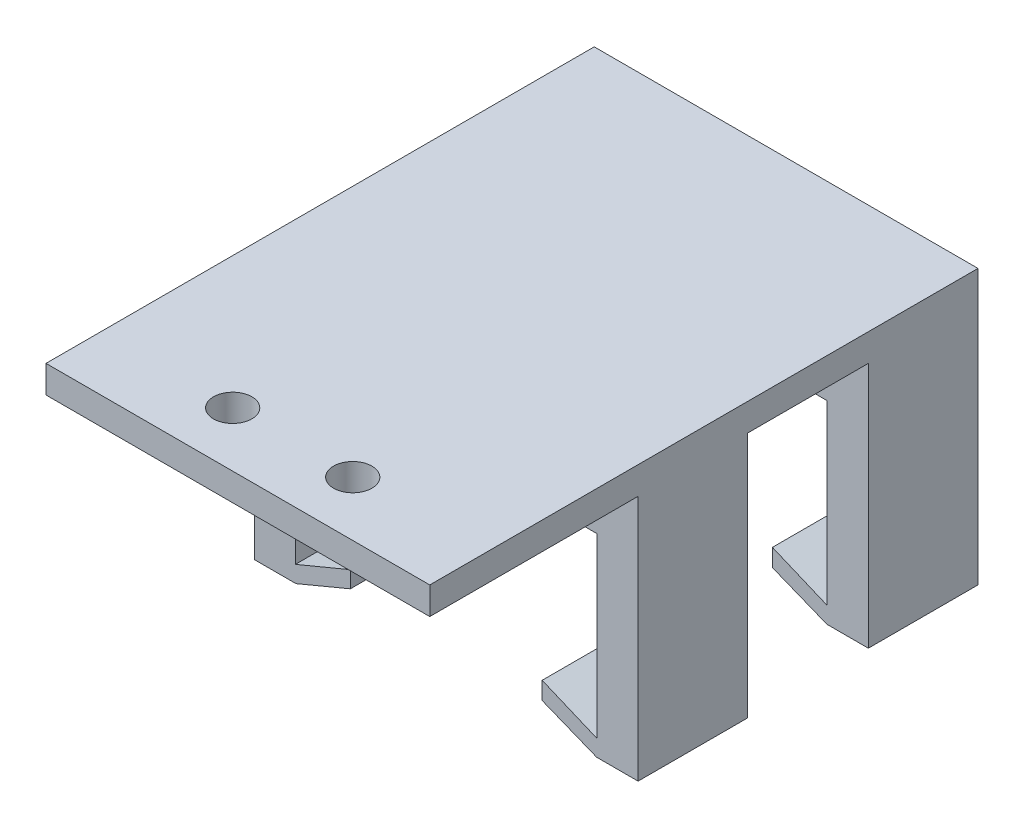
from build123d import *

# Parameters (mm, degrees)
SKETCH3_W           = 35.56
SKETCH3_H           = 50.8
SKETCH3_R           = 1.778
BOSS_EXTRUDE3_DEPTH = 2.54
SKETCH4_W           = 3.81
SKETCH4_H           = 36.576
BOSS_EXTRUDE4_DEPTH = 22.86
SKETCH5_W           = 36.576
SKETCH5_H           = 1.524
BOSS_EXTRUDE5_DEPTH = 5.08
SKETCH6_W           = 36.576
SKETCH6_H           = 1.524
BOSS_EXTRUDE6_DEPTH = 5.08
SKETCH7_W           = 35.56
SKETCH7_H           = 22.86
CUT_EXTRUDE1_DEPTH  = 5.08
SKETCH11_W          = 35.56
SKETCH11_H          = 31.496
BOSS_EXTRUDE7_DEPTH = 4.9022
BOSS_EXTRUDE8_DEPTH = 31.496
SKETCH8_W           = 11.176
SKETCH8_H           = 22.86
CUT_EXTRUDE2_DEPTH  = 36.56
CUT_EXTRUDE3_DEPTH  = 32.496


with BuildPart() as part:
    # Sketch3 → Boss-Extrude3 (new body)
    with BuildSketch(Plane(origin=(0, 0, 0), x_dir=(1, 0, 0), z_dir=(0, 1, 0))):
        with Locations((6.262748092, -12.959016216)):
            Rectangle(SKETCH3_W, SKETCH3_H)
        with Locations((0.700148092, -33.279016216)):
            Circle(SKETCH3_R, mode=Mode.SUBTRACT)
        with Locations((11.825348092, -33.279016216)):
            Circle(SKETCH3_R, mode=Mode.SUBTRACT)
    extrude(amount=BOSS_EXTRUDE3_DEPTH)

    # Sketch4 → Boss-Extrude4 (add)
    with BuildSketch(Plane.XZ):
        with Locations((-9.612251908, 5.847016216)):
            Rectangle(SKETCH4_W, SKETCH4_H)
        with Locations((22.137748092, 5.847016216)):
            Rectangle(SKETCH4_W, SKETCH4_H)
    extrude(amount=BOSS_EXTRUDE4_DEPTH)

    # Sketch5 → Boss-Extrude5 (add)
    with BuildSketch(Plane(origin=(-7.707251908, 0, 0), x_dir=(0, 0, -1), z_dir=(1, 0, 0))):
        with Locations((-5.847016216, -22.098)):
            Rectangle(SKETCH5_W, SKETCH5_H)
    extrude(amount=BOSS_EXTRUDE5_DEPTH)

    # Sketch6 → Boss-Extrude6 (add)
    with BuildSketch(Plane.ZY.offset(-20.232748092)):
        with Locations((5.847016216, -22.098)):
            Rectangle(SKETCH6_W, SKETCH6_H)
    extrude(amount=BOSS_EXTRUDE6_DEPTH)

    # Sketch7 → Cut-Extrude1 (cut)
    with BuildSketch(Plane.XY.offset(24.135016216)):
        with Locations((6.262748092, -11.43)):
            Rectangle(SKETCH7_W, SKETCH7_H)
    extrude(amount=-CUT_EXTRUDE1_DEPTH, mode=Mode.SUBTRACT)

    # Sketch11 → Boss-Extrude7 (add)
    with BuildSketch(Plane.XZ):
        with Locations((6.262748092, 3.307016216)):
            Rectangle(SKETCH11_W, SKETCH11_H)
    extrude(amount=BOSS_EXTRUDE7_DEPTH)

    # Sketch12 → Boss-Extrude8 (add)
    with BuildSketch(Plane.XY.offset(19.055016216)):
        Polygon((-7.707251908, -21.336), (-2.593407451, -19.20881978), (-2.627251908, -21.336), align=None)
        Polygon((15.152748092, -21.336), (15.152748092, -19.20881978), (20.232748092, -21.336), align=None)
    extrude(amount=-BOSS_EXTRUDE8_DEPTH)

    # Sketch8 → Cut-Extrude2 (cut, through all)
    with BuildSketch(Plane(origin=(24.042748092, 0, 0), x_dir=(0, 0, -1), z_dir=(1, 0, 0))):
        with Locations((-3.307016216, -11.43)):
            Rectangle(SKETCH8_W, SKETCH8_H)
    extrude(amount=-CUT_EXTRUDE2_DEPTH, mode=Mode.SUBTRACT)

    # Sketch13 → Cut-Extrude3 (cut, through all)
    with BuildSketch(Plane.XY.offset(19.055016216)):
        Polygon((-7.660745747, -22.86), (-2.618035473, -20.756731792), (-2.627251908, -22.86), align=None)
        Polygon((15.152748092, -22.86), (20.204845905, -22.86), (15.152748092, -20.834602636), align=None)
    extrude(amount=-CUT_EXTRUDE3_DEPTH, mode=Mode.SUBTRACT)


solid = part.part
